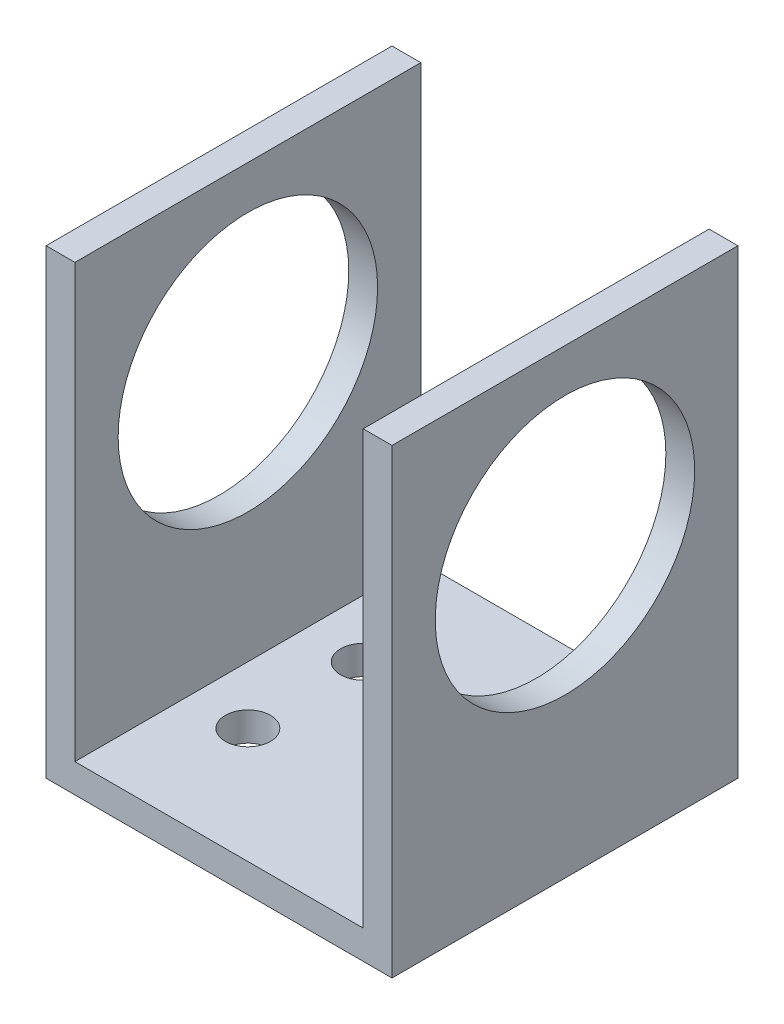
from build123d import *

# Parameters (mm, degrees)
BOSS_EXTRUDE1_DEPTH = 38.1
SKETCH2_R           = 14.2875
CUT_EXTRUDE1_DEPTH  = 39.1
SKETCH3_R           = 2.4892
CUT_EXTRUDE2_DEPTH  = 4.175


with BuildPart() as part:
    # Sketch1 → Boss-Extrude1 (new body)
    with BuildSketch(Plane.XY):
        Polygon((0, 0), (0, 50.8), (3.175, 50.8), (3.175, 3.175), (34.925, 3.175), (34.925, 50.8), (38.1, 50.8), (38.1, 0), align=None)
    extrude(amount=BOSS_EXTRUDE1_DEPTH)

    # Sketch2 → Cut-Extrude1 (cut, through all)
    with BuildSketch(Plane(origin=(38.1, 0, 0), x_dir=(0, 0, -1), z_dir=(1, 0, 0))):
        with Locations((-19.05, 31.75)):
            Circle(SKETCH2_R)
    extrude(amount=-CUT_EXTRUDE1_DEPTH, mode=Mode.SUBTRACT)

    # Sketch3 → Cut-Extrude2 (cut, through all)
    with BuildSketch(Plane(origin=(0, 3.175, 0), x_dir=(1, 0, 0), z_dir=(0, 1, 0))):
        with Locations((9.525, -12.7)):
            Circle(SKETCH3_R)
        with Locations((9.525, -25.4)):
            Circle(SKETCH3_R)
        with Locations((28.575, -25.4)):
            Circle(SKETCH3_R)
        with Locations((28.575, -12.7)):
            Circle(SKETCH3_R)
    extrude(amount=-CUT_EXTRUDE2_DEPTH, mode=Mode.SUBTRACT)


solid = part.part
